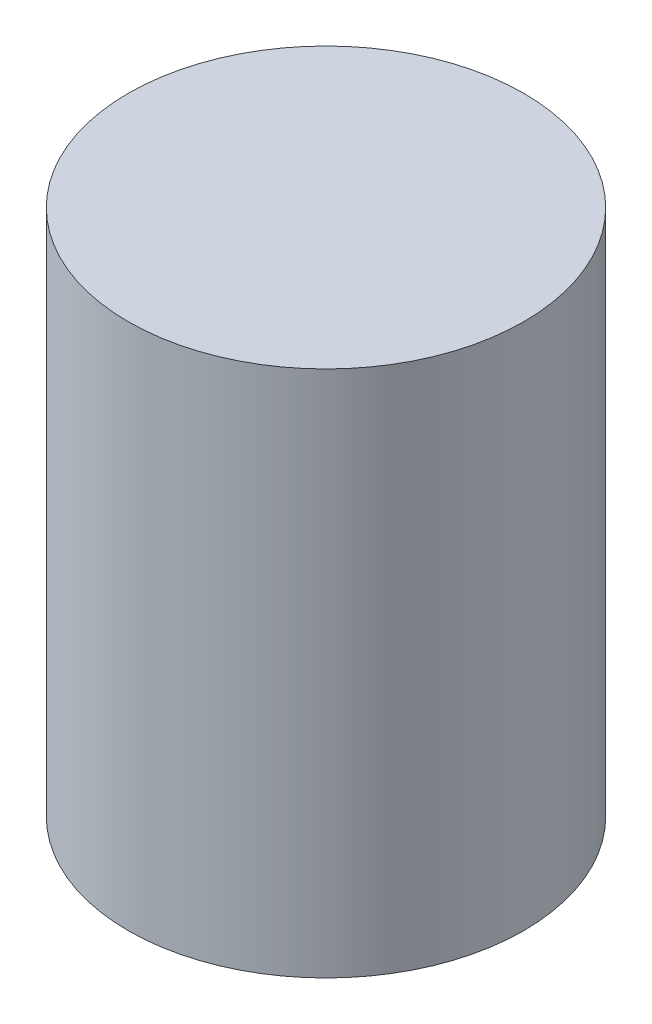
from build123d import *

# Parameters (mm, degrees)
SKETCH1_R           = 1.5
BOSS_EXTRUDE1_DEPTH = 4


with BuildPart() as part:
    # Sketch1 → Boss-Extrude1 (new body)
    with BuildSketch(Plane(origin=(0, 0, 0), x_dir=(1, 0, 0), z_dir=(0, 1, 0))):
        Circle(SKETCH1_R)
    extrude(amount=BOSS_EXTRUDE1_DEPTH)


solid = part.part
